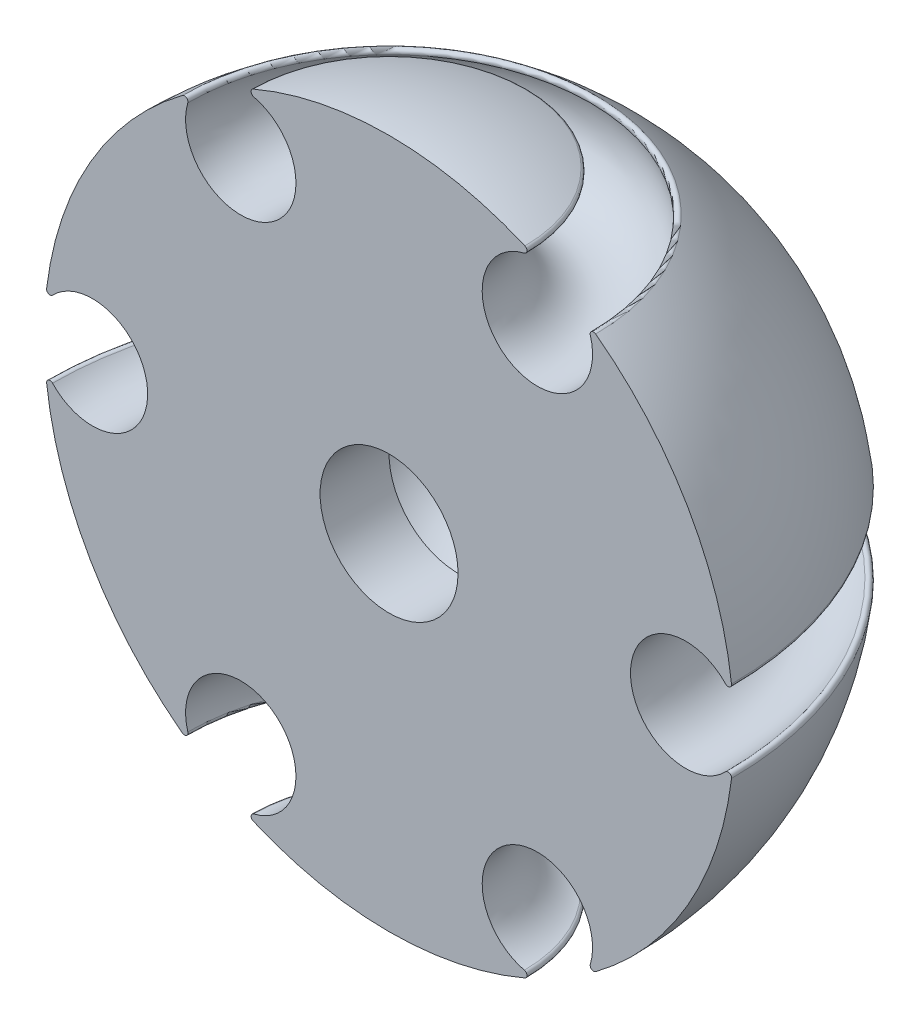
from build123d import *

# Parameters (mm, degrees)
REVOLVE2_ANGLE     = 180
SKETCH2_R          = 10
CUT_EXTRUDE1_DEPTH = 10


with BuildPart() as part:
    # Sketch1 → Revolve2 (revolve)
    with BuildSketch(Plane.XY):
        with BuildLine():
            Line((0, 100), (0, 0))
            ThreePointArc((0, 0), (10.05126544, 1.020697606), (19.692158778, 4.041117478))
            ThreePointArc((19.692158778, 4.041117478), (19.993501156, 4.542335866), (19.613164414, 4.986600499))
            ThreePointArc((19.613164414, 4.986600499), (17.5, 19.689110868), (29.176165271, 10.507801618))
            ThreePointArc((29.176165271, 10.507801618), (29.370741359, 9.956288021), (29.955480404, 9.966648982))
            ThreePointArc((29.955480404, 9.966648982), (43.301270189, 25), (49.647639183, 44.074468496))
            ThreePointArc((49.647639183, 44.074468496), (49.364242515, 44.586047845), (48.789329685, 44.478798881))
            ThreePointArc((48.789329685, 44.478798881), (35, 50), (48.789329685, 55.521201119))
            ThreePointArc((48.789329685, 55.521201119), (49.364242515, 55.413952155), (49.647639183, 55.925531504))
            ThreePointArc((49.647639183, 55.925531504), (43.301270189, 75), (29.955480404, 90.033351018))
            ThreePointArc((29.955480404, 90.033351018), (29.370741359, 90.043711979), (29.176165271, 89.492198382))
            ThreePointArc((29.176165271, 89.492198382), (17.5, 80.310889132), (19.613164414, 95.013399501))
            ThreePointArc((19.613164414, 95.013399501), (19.993501156, 95.457664134), (19.692158778, 95.958882522))
            ThreePointArc((19.692158778, 95.958882522), (10.05126544, 98.979302394), (0, 100))
        make_face()
    revolve(axis=Axis((0, 47.658177132, 0), (0, 1, 0)), revolution_arc=REVOLVE2_ANGLE)

    # Sketch2 → Cut-Extrude1 (cut)
    with BuildSketch(Plane.XY):
        with Locations((0, 50)):
            Circle(SKETCH2_R)
    extrude(amount=-CUT_EXTRUDE1_DEPTH, mode=Mode.SUBTRACT)

    # Sketch5 → Cut-Revolve2 (revolve, cut)
    with BuildSketch(Plane(origin=(0, 50, 0), x_dir=(1, 0, 0), z_dir=(0, 1, 0))):
        with BuildLine():
            ThreePointArc((0, 25), (10.606601718, 20.606601718), (15, 10))
            Line((15, 10), (0, 10))
            Line((0, 10), (0, 25))
        make_face()
    revolve(axis=Axis((0, 50, 0), (0, 0, -1)), mode=Mode.SUBTRACT)


solid = part.part
